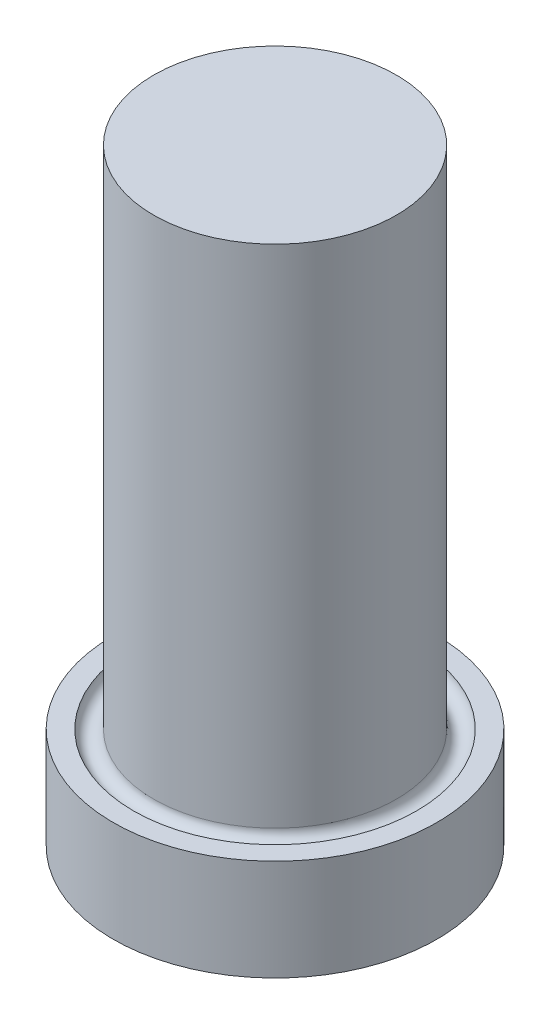
from build123d import *


with BuildPart() as part:
    # Sketch1 → Revolve1 (revolve)
    with BuildSketch(Plane.XY):
        with BuildLine():
            Line((0, 0), (6, 0))
            Line((6, 0), (6, -25))
            ThreePointArc((6, -25), (6.5, -25.5), (7, -25))
            Line((7, -25), (8, -25))
            Line((8, -25), (8, -30))
            Line((8, -30), (0, -30))
            Line((0, -30), (0, -25))
            Line((0, -25), (0, 0))
        make_face()
    revolve(axis=Axis((0, 0, 0), (0, -1, 0)))


solid = part.part
